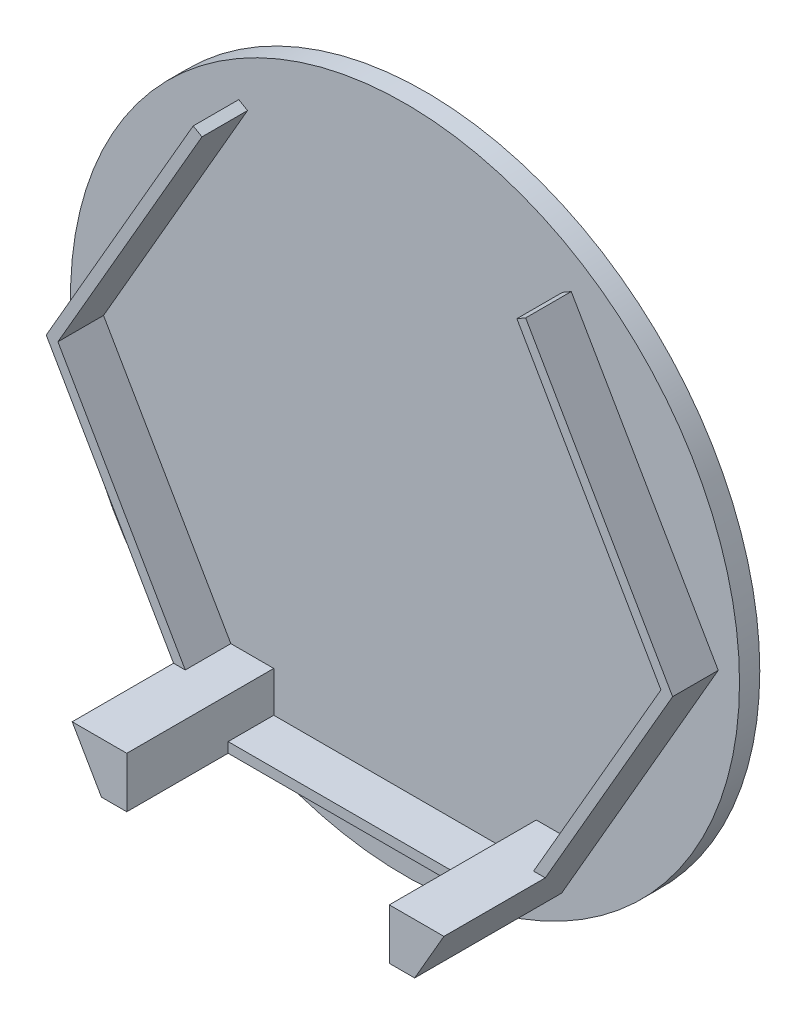
from build123d import *

# Parameters (mm, degrees)
SKETCH1_R           = 33
BOSS_EXTRUDE1_DEPTH = 2
BOSS_EXTRUDE2_DEPTH = 4.5
BOSS_EXTRUDE3_DEPTH = 10


with BuildPart() as part:
    # Sketch1 → Boss-Extrude1 (new body)
    with BuildSketch(Plane.XY):
        Circle(SKETCH1_R)
    extrude(amount=BOSS_EXTRUDE1_DEPTH)

    # Sketch3 → Boss-Extrude2 (add)
    with BuildSketch(Plane.XY.offset(2)):
        Polygon((-15.533974596, 24.61473671), (-29.745299462, 0), (-17.182050808, -21.760184977), (-12.95, -21.760184977), (-12.95, -25.760184977), (12.95, -25.760184977), (12.95, -21.760184977), (17.182050808, -21.760184977), (29.745299462, 0), (15.533974596, 24.61473671), (16.4, 25.11473671), (30.9, 0), (15.45, -26.760184977), (-15.45, -26.760184977), (-30.9, 0), (-16.4, 25.11473671), align=None)
    extrude(amount=BOSS_EXTRUDE2_DEPTH)

    # Sketch4 → Boss-Extrude3 (add)
    with BuildSketch(Plane.XY.offset(6.5)):
        Polygon((-12.95, -21.760184977), (-18.336751346, -21.760184977), (-15.45, -26.760184977), (-12.95, -26.760184977), align=None)
        Polygon((12.95, -21.760184977), (12.95, -26.760184977), (15.45, -26.760184977), (18.336751346, -21.760184977), align=None)
    extrude(amount=BOSS_EXTRUDE3_DEPTH)


solid = part.part
